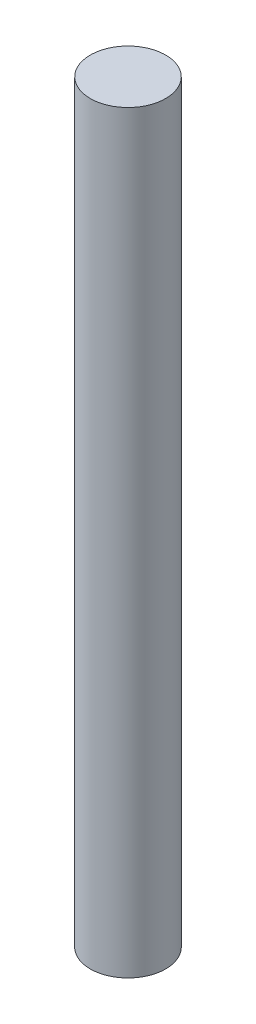
from build123d import *

# Parameters (mm, degrees)
CROQUIS1_R              = 1.5
SALIENTE_EXTRUIR1_DEPTH = 30


with BuildPart() as part:
    # Croquis1 → Saliente-Extruir1 (new body)
    with BuildSketch(Plane(origin=(0, 0, 0), x_dir=(1, 0, 0), z_dir=(0, 1, 0))):
        Circle(CROQUIS1_R)
    extrude(amount=SALIENTE_EXTRUIR1_DEPTH)


solid = part.part
